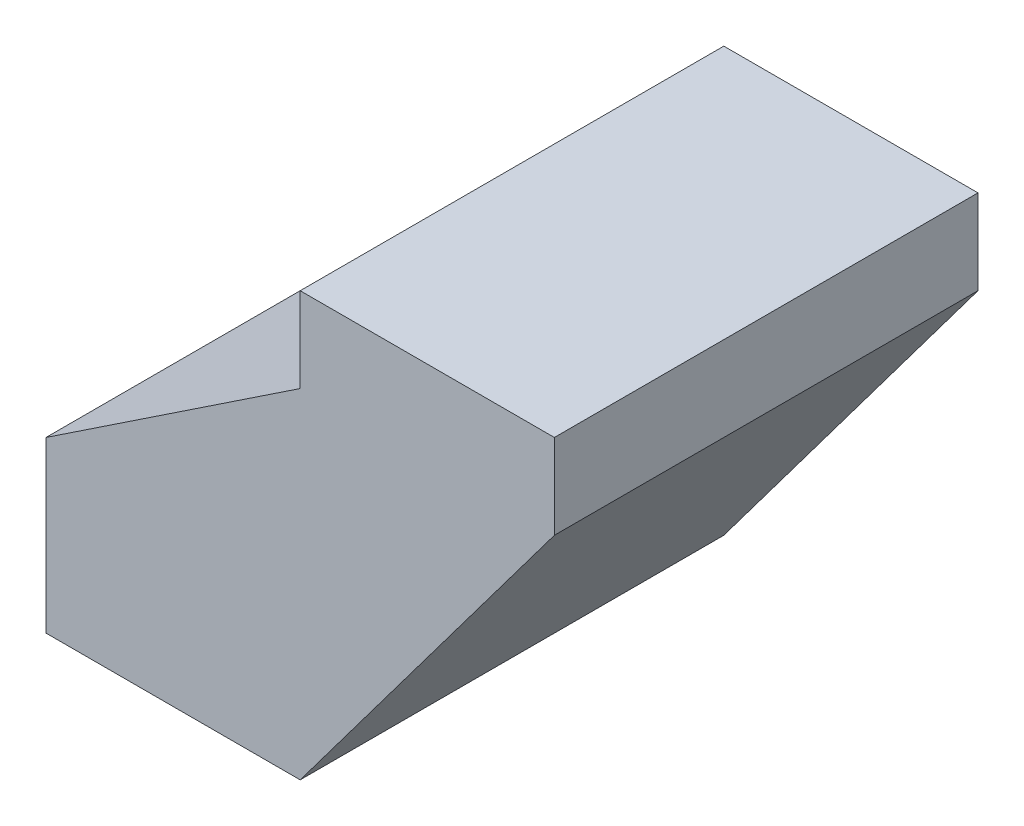
from build123d import *

# Parameters (mm, degrees)
BOSS_EXTRUDE1_DEPTH = 25


with BuildPart() as part:
    # Sketch1 → Boss-Extrude1 (new body)
    with BuildSketch(Plane.XY):
        Polygon((0, 25), (15, 25), (15, 20), (0, 0), (-15, 0), (-15, 10), (0, 20), align=None)
    extrude(amount=BOSS_EXTRUDE1_DEPTH)


solid = part.part
